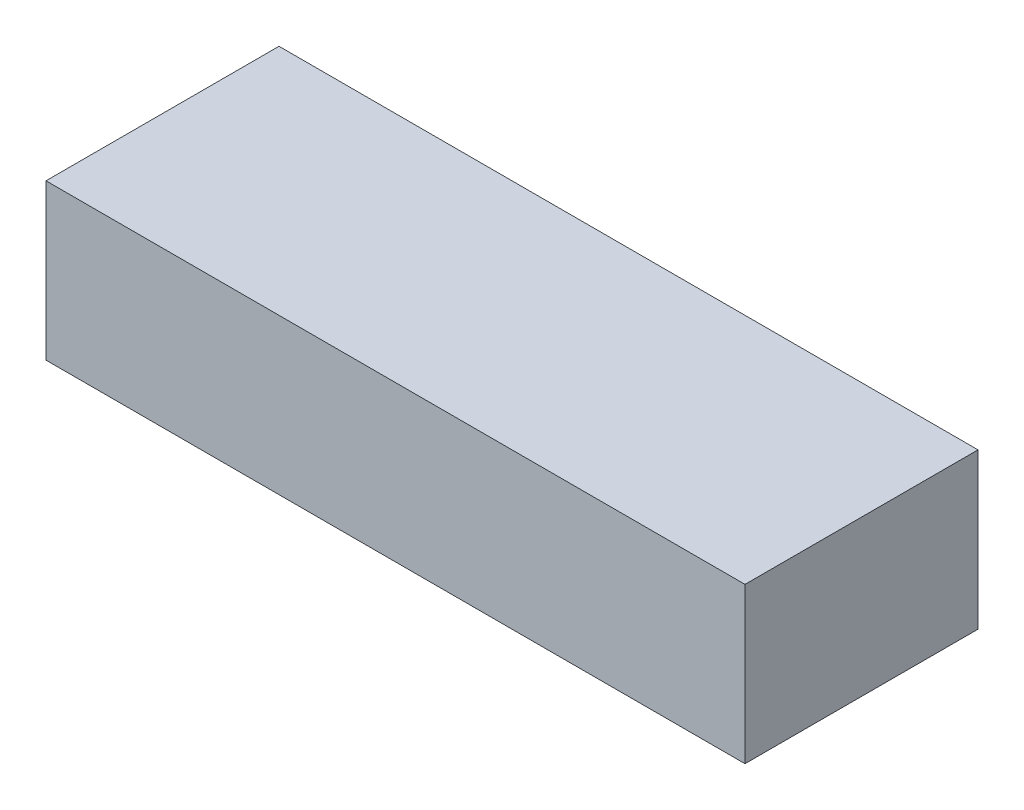
from build123d import *

# Parameters (mm, degrees)
SKETCH1_W           = 90
SKETCH1_H           = 30
BOSS_EXTRUDE1_DEPTH = 20


with BuildPart() as part:
    # Sketch1 → Boss-Extrude1 (new body)
    with BuildSketch(Plane(origin=(0, 0, 0), x_dir=(1, 0, 0), z_dir=(0, 1, 0))):
        with Locations((45, 15)):
            Rectangle(SKETCH1_W, SKETCH1_H)
    extrude(amount=BOSS_EXTRUDE1_DEPTH)


solid = part.part
